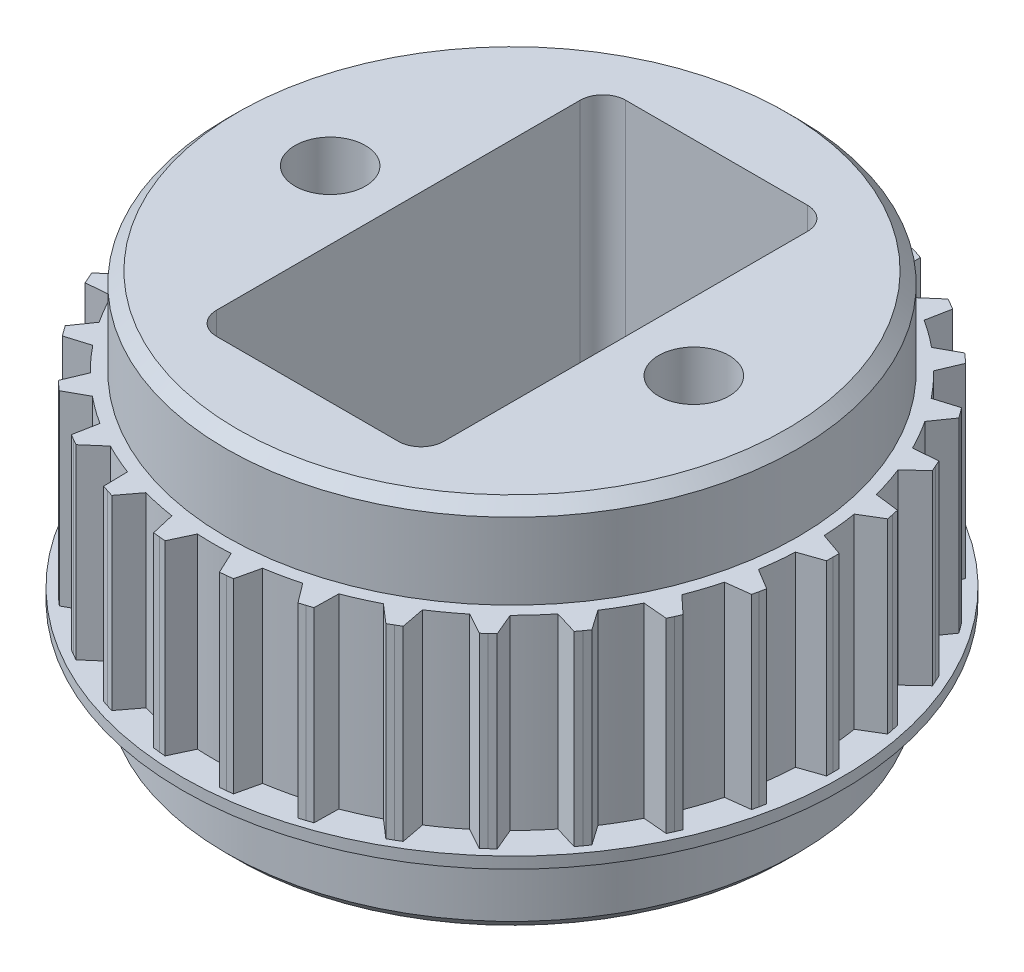
from build123d import *

# Parameters (mm, degrees)
SKETCH3_R               = 13.12
BOSS_EXTRUDE1_DEPTH     = 8.2
BOSS_EXTRUDE2_DEPTH     = 8.2
SKETCH5_R               = 14.5
BOSS_EXTRUDE3_DEPTH     = 0.5
SKETCH6_R               = 12.575
BOSS_EXTRUDE4_DEPTH     = 3.85
SKETCH7_R               = 12.575
BOSS_EXTRUDE5_DEPTH     = 3.85
CHAMFER1_SIZE           = 0.5
SKETCH8_W               = 10
SKETCH8_H               = 18
CUT_EXTRUDE1_DEPTH      = 1
CUT_EXTRUDE1_DEPTH_BACK = 17.4
SKETCH9_R               = 1.55
CUT_EXTRUDE2_DEPTH      = 1
CUT_EXTRUDE2_DEPTH_BACK = 17.4
FILLET1_R               = 1


with BuildPart() as part:
    # Sketch3 → Boss-Extrude1 (new body)
    with BuildSketch(Plane(origin=(0, 0, 0), x_dir=(1, 0, 0), z_dir=(0, 1, 0))):
        Circle(SKETCH3_R)
    extrude(amount=BOSS_EXTRUDE1_DEPTH)

    # Sketch4 → Boss-Extrude2 (add)
    with BuildSketch(Plane(origin=(0, 0, 0), x_dir=(1, 0, 0), z_dir=(0, 1, 0))):
        with BuildLine():
            Line((-14.117223523, -0.28), (-12.849948906, -0.718131678))
            ThreePointArc((-12.849948906, -0.718131678), (-12.87, 1.758e-06), (-12.84994871, 0.718135188))
            Line((-12.84994871, 0.718135188), (-14.117223796, 0.279986237))
            Line((-14.117223796, 0.279986237), (-14.12, 0))
            Line((-14.12, 0), (-14.117223523, -0.28))
        make_face()
        with BuildLine():
            Line((-13.866943592, 2.661254484), (-12.718454664, 1.969215826))
            ThreePointArc((-12.718454664, 1.969215826), (-12.588759256, 2.67582518), (-12.419837799, 3.374096774))
            Line((-12.419837799, 3.374096774), (-13.750516173, 3.209003735))
            Line((-13.750516173, 3.209003735), (-13.811444122, 2.935713074))
            Line((-13.811444122, 2.935713074), (-13.866943592, 2.661254484))
        make_face()
        with BuildLine():
            Line((-13.010611684, 5.486199377), (-12.031102922, 4.570499149))
            ThreePointArc((-12.031102922, 4.570499149), (-11.757329325, 5.234702202), (-11.446920379, 5.882594141))
            Line((-11.446920379, 5.882594141), (-12.782845011, 5.997772371))
            Line((-12.782845011, 5.997772371), (-12.899261862, 5.7431214))
            Line((-12.899261862, 5.7431214), (-13.010611684, 5.486199377))
        make_face()
        with BuildLine():
            Line((-11.585653614, 8.071371032), (-10.817934252, 6.972029728))
            ThreePointArc((-10.817934252, 6.972029728), (-10.412047685, 7.564797619), (-9.973717611, 8.133993916))
            Line((-9.973717611, 8.133993916), (-11.256502184, 8.524409574))
            Line((-11.256502184, 8.524409574), (-11.423319961, 8.299527762))
            Line((-11.423319961, 8.299527762), (-11.585653614, 8.071371032))
        make_face()
        with BuildLine():
            Line((-9.654346887, 10.303785041), (-9.131969944, 9.068849152))
            ThreePointArc((-9.131969944, 9.068849152), (-8.611709598, 9.56427508), (-8.064615523, 10.029899125))
            Line((-8.064615523, 10.029899125), (-9.238196196, 10.678489174))
            Line((-9.238196196, 10.678489174), (-9.448124162, 10.493204936))
            Line((-9.448124162, 10.493204936), (-9.654346887, 10.303785041))
        make_face()
        with BuildLine():
            Line((-7.301098875, 12.085874202), (-7.04689473, 10.769316351))
            ThreePointArc((-7.04689473, 10.769316351), (-6.434998478, 11.145747826), (-5.803051039, 11.487449614))
            Line((-5.803051039, 11.487449614), (-6.816136704, 12.365867557))
            Line((-6.816136704, 12.365867557), (-7.06, 12.228278701))
            Line((-7.06, 12.228278701), (-7.301098875, 12.085874202))
        make_face()
        with BuildLine():
            Line((-4.628757807, 13.339752665), (-4.653836401, 11.999112749))
            ThreePointArc((-4.653836401, 11.999112749), (-3.977047046, 12.240097908), (-3.287865378, 12.442943432))
            Line((-3.287865378, 12.442943432), (-4.096179332, 13.512798189))
            Line((-4.096179332, 13.512798189), (-4.363319961, 13.42891801))
            Line((-4.363319961, 13.42891801), (-4.628757807, 13.339752665))
        make_face()
        with BuildLine():
            Line((-1.754117811, 14.010619926), (-2.05738309, 12.704490341))
            ThreePointArc((-2.05738309, 12.704490341), (-1.345279574, 12.799496977), (-0.628984223, 12.854620914))
            Line((-0.628984223, 12.854620914), (-1.197199266, 14.069154698))
            Line((-1.197199266, 14.069154698), (-1.475941901, 14.042649163))
            Line((-1.475941901, 14.042649163), (-1.754117811, 14.010619926))
        make_face()
        with BuildLine():
            Line((1.19718555, 14.069155865), (0.628987734, 12.854620742))
            ThreePointArc((0.628987734, 12.854620742), (1.34528307, 12.79949661), (2.05738656, 12.704489779))
            Line((2.05738656, 12.704489779), (1.754104152, 14.010621636))
            Line((1.754104152, 14.010621636), (1.475941901, 14.042649163))
            Line((1.475941901, 14.042649163), (1.19718555, 14.069155865))
        make_face()
        with BuildLine():
            Line((4.096166157, 13.512802182), (3.287868777, 12.442942534))
            ThreePointArc((3.287868777, 12.442942534), (3.977050389, 12.240096822), (4.653839678, 11.999111477))
            Line((4.653839678, 11.999111477), (4.628744801, 13.339757178))
            Line((4.628744801, 13.339757178), (4.363319961, 13.42891801))
            Line((4.363319961, 13.42891801), (4.096166157, 13.512802182))
        make_face()
        with BuildLine():
            Line((6.816124648, 12.365874202), (5.803054176, 11.487448029))
            ThreePointArc((5.803054176, 11.487448029), (6.435001522, 11.145746068), (7.046897671, 10.769314426))
            Line((7.046897671, 10.769314426), (7.301087092, 12.08588132))
            Line((7.301087092, 12.08588132), (7.06, 12.228278701))
            Line((7.06, 12.228278701), (6.816124648, 12.365874202))
        make_face()
        with BuildLine():
            Line((9.238185785, 10.678498181), (8.064618263, 10.029896923))
            ThreePointArc((8.064618263, 10.029896923), (8.61171221, 9.564272728), (9.131972421, 9.068846658))
            Line((9.131972421, 9.068846658), (9.654336842, 10.303794454))
            Line((9.654336842, 10.303794454), (9.448124162, 10.493204936))
            Line((9.448124162, 10.493204936), (9.238185785, 10.678498181))
        make_face()
        with BuildLine():
            Line((11.256493873, 8.524420549), (9.973719832, 8.133991192))
            ThreePointArc((9.973719832, 8.133991192), (10.412049751, 7.564794775), (10.817936156, 6.972026773))
            Line((10.817936156, 6.972026773), (11.585645745, 8.071382327))
            Line((11.585645745, 8.071382327), (11.423319961, 8.299527762))
            Line((11.423319961, 8.299527762), (11.256493873, 8.524420549))
        make_face()
        with BuildLine():
            Line((12.782839164, 5.997784833), (11.446921986, 5.882591015))
            ThreePointArc((11.446921986, 5.882591015), (11.757330755, 5.234698991), (12.031104171, 4.570495863))
            Line((12.031104171, 4.570495863), (13.010606335, 5.486212062))
            Line((13.010606335, 5.486212062), (12.899261862, 5.7431214))
            Line((12.899261862, 5.7431214), (12.782839164, 5.997784833))
        make_face()
        with BuildLine():
            Line((13.750513045, 3.209017141), (12.419838721, 3.374093382))
            ThreePointArc((12.419838721, 3.374093382), (12.588759987, 2.675821742), (12.718455201, 1.969212352))
            Line((12.718455201, 1.969212352), (13.866940997, 2.661268004))
            Line((13.866940997, 2.661268004), (13.811444122, 2.935713074))
            Line((13.811444122, 2.935713074), (13.750513045, 3.209017141))
        make_face()
        with BuildLine():
            Line((14.117223523, 0.28), (12.849948906, 0.718131678))
            ThreePointArc((12.849948906, 0.718131678), (12.87, -1.758e-06), (12.84994871, -0.718135188))
            Line((12.84994871, -0.718135188), (14.117223796, -0.279986237))
            Line((14.117223796, -0.279986237), (14.12, 0))
            Line((14.12, 0), (14.117223523, 0.28))
        make_face()
        with BuildLine():
            Line((13.866943592, -2.661254484), (12.718454664, -1.969215826))
            ThreePointArc((12.718454664, -1.969215826), (12.588759256, -2.67582518), (12.419837799, -3.374096774))
            Line((12.419837799, -3.374096774), (13.750516173, -3.209003735))
            Line((13.750516173, -3.209003735), (13.811444122, -2.935713074))
            Line((13.811444122, -2.935713074), (13.866943592, -2.661254484))
        make_face()
        with BuildLine():
            Line((13.010611684, -5.486199377), (12.031102922, -4.570499149))
            ThreePointArc((12.031102922, -4.570499149), (11.757329325, -5.234702202), (11.446920379, -5.882594141))
            Line((11.446920379, -5.882594141), (12.782845011, -5.997772371))
            Line((12.782845011, -5.997772371), (12.899261862, -5.7431214))
            Line((12.899261862, -5.7431214), (13.010611684, -5.486199377))
        make_face()
        with BuildLine():
            Line((11.585653614, -8.071371032), (10.817934252, -6.972029728))
            ThreePointArc((10.817934252, -6.972029728), (10.412047685, -7.564797619), (9.973717611, -8.133993916))
            Line((9.973717611, -8.133993916), (11.256502184, -8.524409574))
            Line((11.256502184, -8.524409574), (11.423319961, -8.299527762))
            Line((11.423319961, -8.299527762), (11.585653614, -8.071371032))
        make_face()
        with BuildLine():
            Line((9.654346887, -10.303785041), (9.131969944, -9.068849152))
            ThreePointArc((9.131969944, -9.068849152), (8.611709598, -9.56427508), (8.064615523, -10.029899125))
            Line((8.064615523, -10.029899125), (9.238196196, -10.678489174))
            Line((9.238196196, -10.678489174), (9.448124162, -10.493204936))
            Line((9.448124162, -10.493204936), (9.654346887, -10.303785041))
        make_face()
        with BuildLine():
            Line((7.301098875, -12.085874202), (7.04689473, -10.769316351))
            ThreePointArc((7.04689473, -10.769316351), (6.434998478, -11.145747826), (5.803051039, -11.487449614))
            Line((5.803051039, -11.487449614), (6.816136704, -12.365867557))
            Line((6.816136704, -12.365867557), (7.06, -12.228278701))
            Line((7.06, -12.228278701), (7.301098875, -12.085874202))
        make_face()
        with BuildLine():
            Line((4.628757807, -13.339752665), (4.653836401, -11.999112749))
            ThreePointArc((4.653836401, -11.999112749), (3.977047046, -12.240097908), (3.287865378, -12.442943432))
            Line((3.287865378, -12.442943432), (4.096179332, -13.512798189))
            Line((4.096179332, -13.512798189), (4.363319961, -13.42891801))
            Line((4.363319961, -13.42891801), (4.628757807, -13.339752665))
        make_face()
        with BuildLine():
            Line((1.754117811, -14.010619926), (2.05738309, -12.704490341))
            ThreePointArc((2.05738309, -12.704490341), (1.345279574, -12.799496977), (0.628984223, -12.854620914))
            Line((0.628984223, -12.854620914), (1.197199266, -14.069154698))
            Line((1.197199266, -14.069154698), (1.475941901, -14.042649163))
            Line((1.475941901, -14.042649163), (1.754117811, -14.010619926))
        make_face()
        with BuildLine():
            Line((-1.19718555, -14.069155865), (-0.628987734, -12.854620742))
            ThreePointArc((-0.628987734, -12.854620742), (-1.34528307, -12.79949661), (-2.05738656, -12.704489779))
            Line((-2.05738656, -12.704489779), (-1.754104152, -14.010621636))
            Line((-1.754104152, -14.010621636), (-1.475941901, -14.042649163))
            Line((-1.475941901, -14.042649163), (-1.19718555, -14.069155865))
        make_face()
        with BuildLine():
            Line((-4.096166157, -13.512802182), (-3.287868777, -12.442942534))
            ThreePointArc((-3.287868777, -12.442942534), (-3.977050389, -12.240096822), (-4.653839678, -11.999111477))
            Line((-4.653839678, -11.999111477), (-4.628744801, -13.339757178))
            Line((-4.628744801, -13.339757178), (-4.363319961, -13.42891801))
            Line((-4.363319961, -13.42891801), (-4.096166157, -13.512802182))
        make_face()
        with BuildLine():
            Line((-6.816124648, -12.365874202), (-5.803054176, -11.487448029))
            ThreePointArc((-5.803054176, -11.487448029), (-6.435001522, -11.145746068), (-7.046897671, -10.769314426))
            Line((-7.046897671, -10.769314426), (-7.301087092, -12.08588132))
            Line((-7.301087092, -12.08588132), (-7.06, -12.228278701))
            Line((-7.06, -12.228278701), (-6.816124648, -12.365874202))
        make_face()
        with BuildLine():
            Line((-9.238185785, -10.678498181), (-8.064618263, -10.029896923))
            ThreePointArc((-8.064618263, -10.029896923), (-8.61171221, -9.564272728), (-9.131972421, -9.068846658))
            Line((-9.131972421, -9.068846658), (-9.654336842, -10.303794454))
            Line((-9.654336842, -10.303794454), (-9.448124162, -10.493204936))
            Line((-9.448124162, -10.493204936), (-9.238185785, -10.678498181))
        make_face()
        with BuildLine():
            Line((-11.256493873, -8.524420549), (-9.973719832, -8.133991192))
            ThreePointArc((-9.973719832, -8.133991192), (-10.412049751, -7.564794775), (-10.817936156, -6.972026773))
            Line((-10.817936156, -6.972026773), (-11.585645745, -8.071382327))
            Line((-11.585645745, -8.071382327), (-11.423319961, -8.299527762))
            Line((-11.423319961, -8.299527762), (-11.256493873, -8.524420549))
        make_face()
        with BuildLine():
            Line((-12.782839164, -5.997784833), (-11.446921986, -5.882591015))
            ThreePointArc((-11.446921986, -5.882591015), (-11.757330755, -5.234698991), (-12.031104171, -4.570495863))
            Line((-12.031104171, -4.570495863), (-13.010606335, -5.486212062))
            Line((-13.010606335, -5.486212062), (-12.899261862, -5.7431214))
            Line((-12.899261862, -5.7431214), (-12.782839164, -5.997784833))
        make_face()
        with BuildLine():
            Line((-13.750513045, -3.209017141), (-12.419838721, -3.374093382))
            ThreePointArc((-12.419838721, -3.374093382), (-12.588759987, -2.675821742), (-12.718455201, -1.969212352))
            Line((-12.718455201, -1.969212352), (-13.866940997, -2.661268004))
            Line((-13.866940997, -2.661268004), (-13.811444122, -2.935713074))
            Line((-13.811444122, -2.935713074), (-13.750513045, -3.209017141))
        make_face()
    extrude(amount=BOSS_EXTRUDE2_DEPTH)

    # Sketch5 → Boss-Extrude3 (add)
    with BuildSketch(Plane.XZ):
        Circle(SKETCH5_R)
    extrude(amount=BOSS_EXTRUDE3_DEPTH)

    # Sketch6 → Boss-Extrude4 (add)
    with BuildSketch(Plane(origin=(0, -0.5, 0), x_dir=(-1, 0, 0), z_dir=(0, -1, 0))):
        Circle(SKETCH6_R)
    extrude(amount=BOSS_EXTRUDE4_DEPTH)

    # Sketch7 → Boss-Extrude5 (add)
    with BuildSketch(Plane(origin=(0, 8.2, 0), x_dir=(1, 0, 0), z_dir=(0, 1, 0))):
        Circle(SKETCH7_R)
    extrude(amount=BOSS_EXTRUDE5_DEPTH)

    # Chamfer1
    chamfer1_edges = [part.edges().sort_by_distance(p)[0] for p in [
        (12.575, -4.35, 0),
        (-12.575, 12.05, 0),
    ]]
    chamfer(chamfer1_edges, length=CHAMFER1_SIZE)

    # Sketch8 → Cut-Extrude1 (cut, two sides)
    with BuildSketch(Plane(origin=(0, 12.05, 0), x_dir=(1, 0, 0), z_dir=(0, 1, 0))) as cut_extrude1_sk:
        Rectangle(SKETCH8_W, SKETCH8_H)
    extrude(amount=CUT_EXTRUDE1_DEPTH, mode=Mode.SUBTRACT)
    extrude(cut_extrude1_sk.sketch, amount=-CUT_EXTRUDE1_DEPTH_BACK, mode=Mode.SUBTRACT)

    # Sketch9 → Cut-Extrude2 (cut, two sides)
    with BuildSketch(Plane(origin=(0, 12.05, 0), x_dir=(1, 0, 0), z_dir=(0, 1, 0))) as cut_extrude2_sk:
        with Locations((-8, 0)):
            Circle(SKETCH9_R)
        with Locations((8, 0)):
            Circle(SKETCH9_R)
    extrude(amount=CUT_EXTRUDE2_DEPTH, mode=Mode.SUBTRACT)
    extrude(cut_extrude2_sk.sketch, amount=-CUT_EXTRUDE2_DEPTH_BACK, mode=Mode.SUBTRACT)

    # Fillet1
    fillet1_edges = [part.edges().sort_by_distance(p)[0] for p in [
        (-5, 3.85, 9),
        (-5, 3.85, -9),
        (5, 3.85, -9),
        (5, 3.85, 9),
    ]]
    fillet(fillet1_edges, radius=FILLET1_R)


solid = part.part
